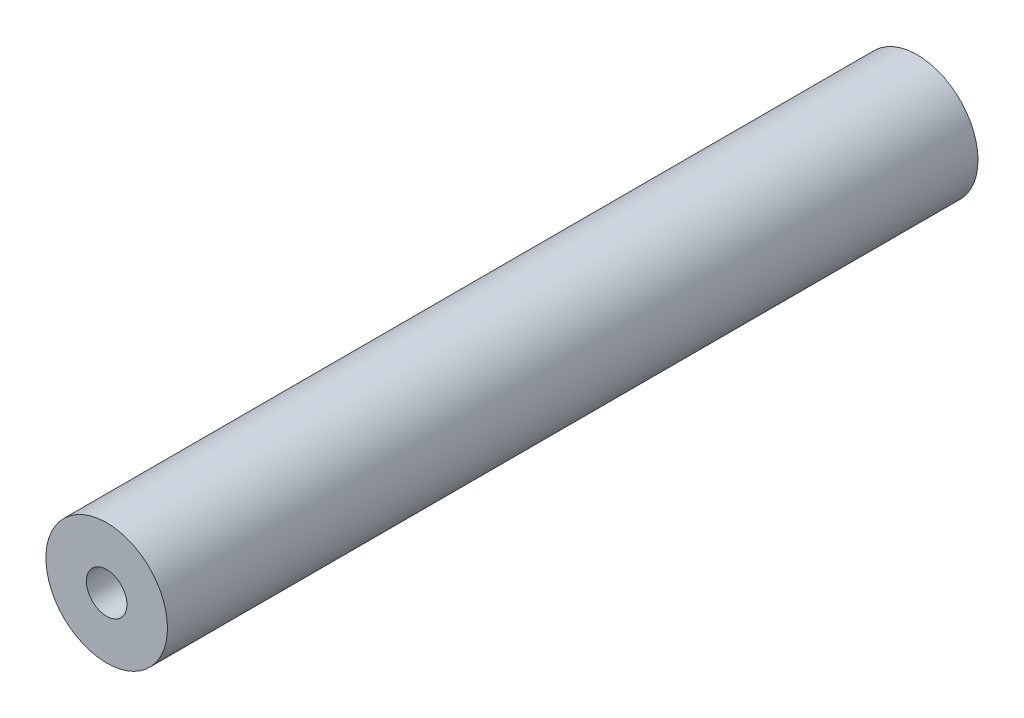
from build123d import *

# Parameters (mm, degrees)
SCHIZZO1_R                   = 1.5
SCHIZZO1_R_2                 = 0.5
ESTRUSIONE_ESTRUSIONE1_DEPTH = 20


with BuildPart() as part:
    # Schizzo1 → Estrusione-Estrusione1 (new body)
    with BuildSketch(Plane.XY):
        Circle(SCHIZZO1_R)
        Circle(SCHIZZO1_R_2, mode=Mode.SUBTRACT)
    extrude(amount=ESTRUSIONE_ESTRUSIONE1_DEPTH)


solid = part.part
